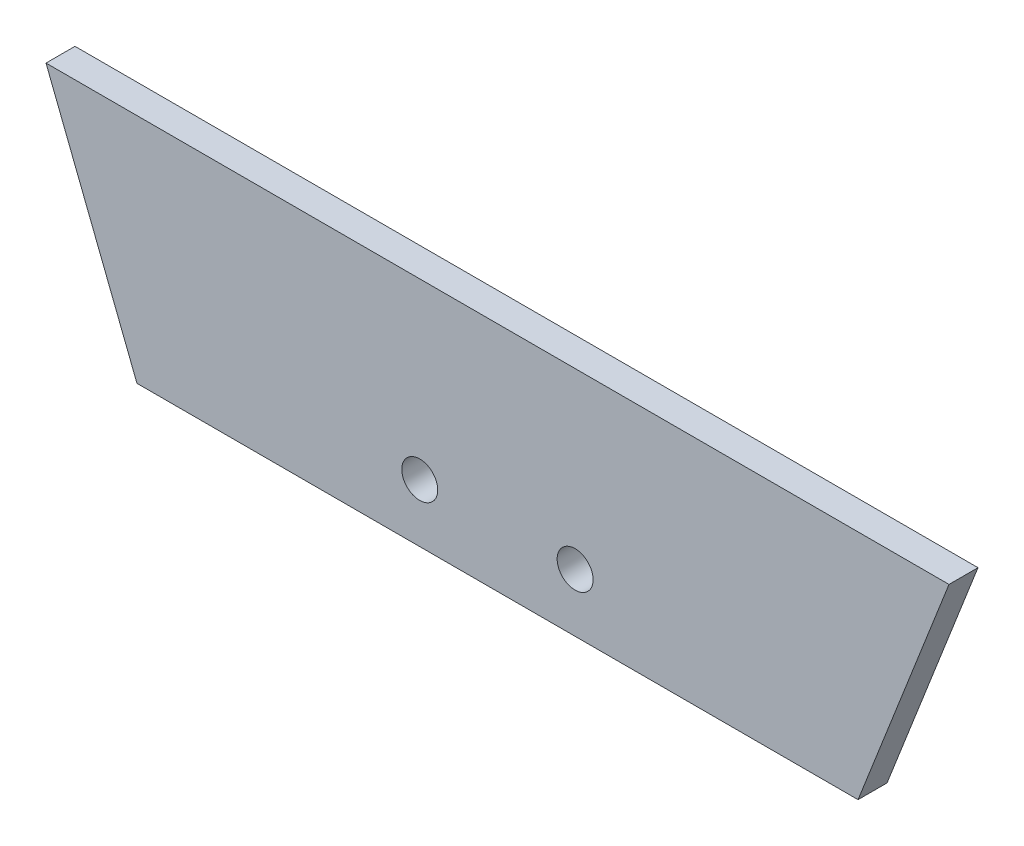
from build123d import *

# Parameters (mm, degrees)
BOSS_EXTRUDE2_DEPTH = 6.35
SKETCH3_R           = 3.937
CUT_EXTRUDE1_DEPTH  = 6.35


with BuildPart() as part:
    # Sketch2 → Boss-Extrude2 (new body)
    with BuildSketch(Plane.XY):
        Polygon((-39.84625, 101.6), (157.95625, 101.6), (138.033125, 50.8), (-19.923125, 50.8), align=None)
    extrude(amount=BOSS_EXTRUDE2_DEPTH)

    # Sketch3 → Cut-Extrude1 (cut)
    with BuildSketch(Plane.XY.offset(6.35)):
        with Locations((42.021125, 63.5)):
            Circle(SKETCH3_R)
        with Locations((76.057125, 63.5)):
            Circle(SKETCH3_R)
    extrude(amount=-CUT_EXTRUDE1_DEPTH, mode=Mode.SUBTRACT)


solid = part.part
